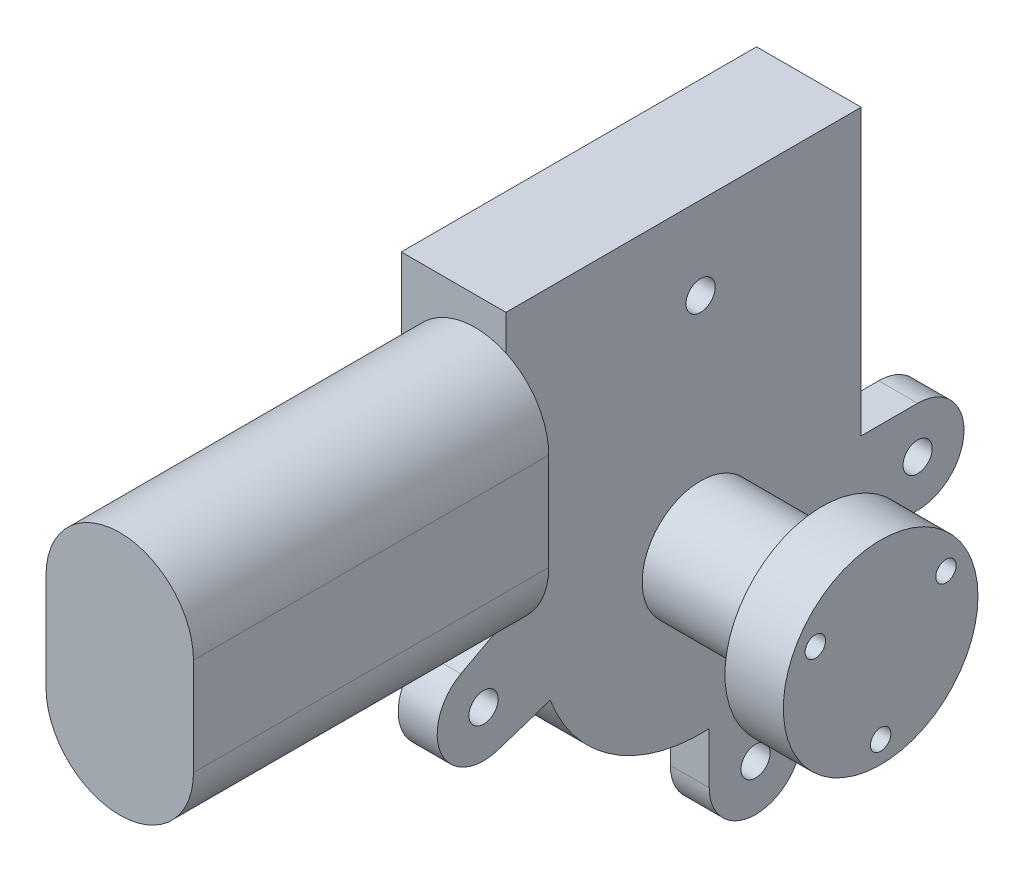
from build123d import *

# Parameters (mm, degrees)
SKETCH1_R                       = 33
BOSS_EXTRUDE1_DEPTH             = 21.5
SKETCH4_R                       = 20
BOSS_EXTRUDE4_DEPTH             = 37
SKETCH6_W                       = 21.5
SKETCH6_H                       = 62
BOSS_EXTRUDE5_DEPTH             = 73
BOSS_EXTRUDE6_DEPTH             = 73
BOSS_EXTRUDE7_DEPTH             = 8
M6X1_0_TAPPED_HOLE1_D           = 5
M6X1_0_TAPPED_HOLE1_DEPTH       = 14.99
M6X1_0_TAPPED_HOLE1_CBORE_D     = 6
M6X1_0_TAPPED_HOLE1_CBORE_DEPTH = 11.94
M6X1_0_TAPPED_HOLE1_TIP         = 1.502151548
M5X0_8_TAPPED_HOLE1_D           = 4.2
M5X0_8_TAPPED_HOLE1_DEPTH       = 12.192
M5X0_8_TAPPED_HOLE1_TIP         = 1.2618073
SKETCH14_W                      = 25
SKETCH14_H                      = 8


with BuildPart() as part:
    # Sketch1 → Boss-Extrude1 (new body)
    with BuildSketch(Plane(origin=(0, 0, 0), x_dir=(0, 0, -1), z_dir=(1, 0, 0))):
        with Locations((-33, 0)):
            Circle(SKETCH1_R)
    extrude(amount=BOSS_EXTRUDE1_DEPTH)

    # Sketch4 → Boss-Extrude4 (add)
    with BuildSketch(Plane(origin=(21.5, 0, 0), x_dir=(0, 0, -1), z_dir=(1, 0, 0))):
        with Locations((-33, 0)):
            Circle(SKETCH4_R)
    extrude(amount=BOSS_EXTRUDE4_DEPTH)

    # Sketch6 → Boss-Extrude5 (add)
    with BuildSketch(Plane.XY):
        with Locations((10.75, 31)):
            Rectangle(SKETCH6_W, SKETCH6_H)
    extrude(amount=BOSS_EXTRUDE5_DEPTH)

    # Sketch7 → Boss-Extrude6 (add)
    with BuildSketch(Plane.XY.offset(73)):
        with BuildLine():
            Line((30.3, 41), (30.3, 21))
            ThreePointArc((30.3, 21), (15.15, 5.85), (0, 21))
            Line((0, 21), (0, 41))
            ThreePointArc((0, 41), (15.15, 56.15), (30.3, 41))
        make_face()
    extrude(amount=BOSS_EXTRUDE6_DEPTH)

    # Sketch9 → Boss-Extrude7 (add)
    with BuildSketch(Plane(origin=(21.5, 0, 0), x_dir=(0, 0, -1), z_dir=(1, 0, 0))):
        with BuildLine():
            Line((11.6, 3.525), (0, 3.525))
            Line((0, 3.525), (-3.880000429, -15.525))
            Line((-3.880000429, -15.525), (11.6, -15.525))
            ThreePointArc((11.6, -15.525), (21.125, -6), (11.6, 3.525))
        make_face()
        with BuildLine():
            Line((-12.175, -43.5), (-12.175, -25.599206531))
            Line((-12.175, -25.599206531), (-31.225, -32.95222868))
            Line((-31.225, -32.95222868), (-31.225, -43.5))
            ThreePointArc((-31.225, -43.5), (-21.7, -53.025), (-12.175, -43.5))
        make_face()
        with BuildLine():
            Line((-82.269569588, 2.301851893), (-73, 7.245000909))
            Line((-73, 7.245000909), (-63.910592017, 7.245000909))
            Line((-63.910592017, 7.245000909), (-63.910592017, -11.555747537))
            Line((-63.910592017, -11.555747537), (-74.647866464, -15.055966684))
            ThreePointArc((-74.647866464, -15.055966684), (-86.321287926, -9.829459741), (-82.269569588, 2.301851893))
        make_face()
    extrude(amount=-BOSS_EXTRUDE7_DEPTH)

    # M6x1.0 Tapped Hole1
    with Locations(Plane(origin=(21.5, 0, 0), x_dir=(0, 0, -1), z_dir=(1, 0, 0))):
        with Locations((-33, 45), (11.6, -6), (-21.7, -43.5), (-77.6, -6)):
            CounterBoreHole(M6X1_0_TAPPED_HOLE1_D / 2, M6X1_0_TAPPED_HOLE1_CBORE_D / 2, M6X1_0_TAPPED_HOLE1_CBORE_DEPTH, depth=M6X1_0_TAPPED_HOLE1_DEPTH)
            with Locations((0, 0, -(M6X1_0_TAPPED_HOLE1_DEPTH + M6X1_0_TAPPED_HOLE1_TIP / 2))):  # 118° drill point
                Cone(0, M6X1_0_TAPPED_HOLE1_D / 2, M6X1_0_TAPPED_HOLE1_TIP, mode=Mode.SUBTRACT)

    # M5x0.8 Tapped Hole1
    with Locations(Plane(origin=(58.5, 0, 0), x_dir=(0, 0, -1), z_dir=(1, 0, 0))):
        with Locations((-19.576606241, 7.75), (-33, -15.5), (-46.423393759, 7.75)):
            Hole(M5X0_8_TAPPED_HOLE1_D / 2, depth=M5X0_8_TAPPED_HOLE1_DEPTH)
            with Locations((0, 0, -(M5X0_8_TAPPED_HOLE1_DEPTH + M5X0_8_TAPPED_HOLE1_TIP / 2))):  # 118° drill point
                Cone(0, M5X0_8_TAPPED_HOLE1_D / 2, M5X0_8_TAPPED_HOLE1_TIP, mode=Mode.SUBTRACT)

    # Sketch14 → Cut-Revolve1 (revolve, cut)
    with BuildSketch(Plane(origin=(0, 0, 0), x_dir=(1, 0, 0), z_dir=(0, 1, 0))):
        with Locations((34, -49)):
            Rectangle(SKETCH14_W, SKETCH14_H)
    revolve(axis=Axis((58.5, 0, 33), (-1, 0, 0)), mode=Mode.SUBTRACT)


solid = part.part
